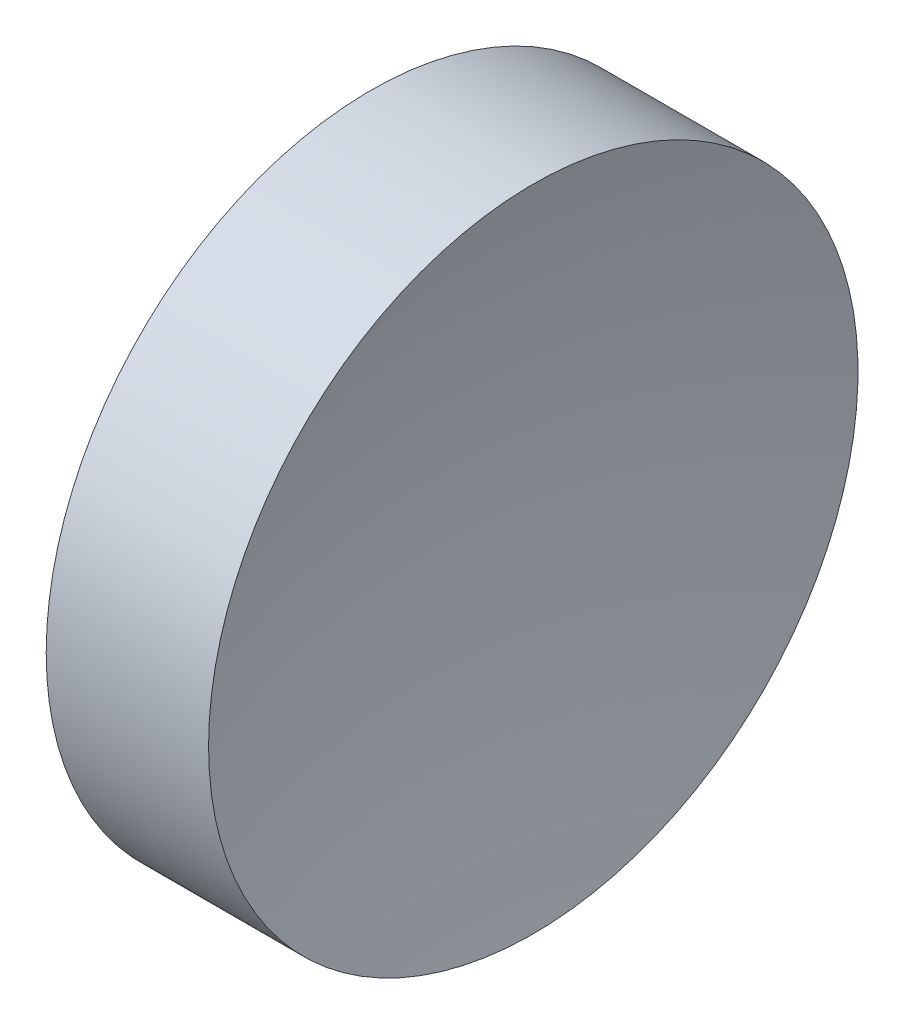
from build123d import *


with BuildPart() as part:
    # 草图1 → 旋转1 (revolve)
    with BuildSketch(Plane(origin=(0, 0, 0), x_dir=(1, 0, 0), z_dir=(0, 1, 0)), mode=Mode.PRIVATE) as revolve_1_sk:
        with BuildLine():
            Line((0, 0), (4.71, 0))
            ThreePointArc((4.71, 0), (5.12164176, 6.402712477), (6.349789082, 12.7))
            Line((6.349789082, 12.7), (0, 12.7))
            Line((0, 12.7), (0, 0))
        make_face()
    revolve(revolve_1_sk.sketch.rotate(Axis((0, 0, 0), (1, 0, 0)), 180), axis=Axis((0, 0, 0), (1, 0, 0)))  # turned: the seam where the file's is


solid = part.part
